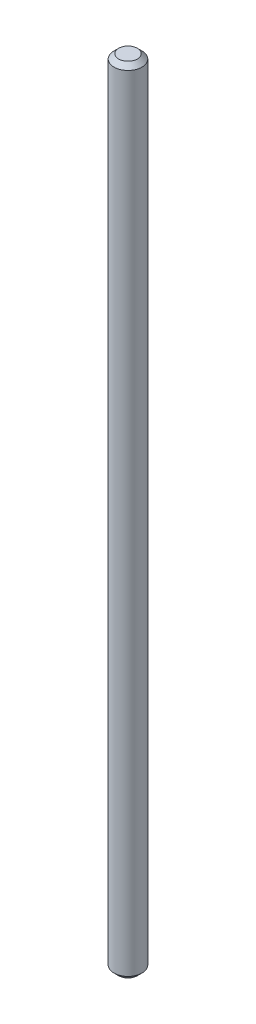
from build123d import *

# Parameters (mm, degrees)
SKETCH2_R           = 1.5
BOSS_EXTRUDE1_DEPTH = 85
CHAMFER1_SIZE       = 0.5


with BuildPart() as part:
    # Sketch2 → Boss-Extrude1 (new body)
    with BuildSketch(Plane(origin=(0, 0, 0), x_dir=(1, 0, 0), z_dir=(0, 1, 0))):
        Circle(SKETCH2_R)
    extrude(amount=BOSS_EXTRUDE1_DEPTH)

    # Chamfer1
    chamfer1_edges = [part.edges().sort_by_distance(p)[0] for p in [
        (-1.5, 0, 0),
        (-1.5, 85, 0),
    ]]
    chamfer(chamfer1_edges, length=CHAMFER1_SIZE)


solid = part.part
